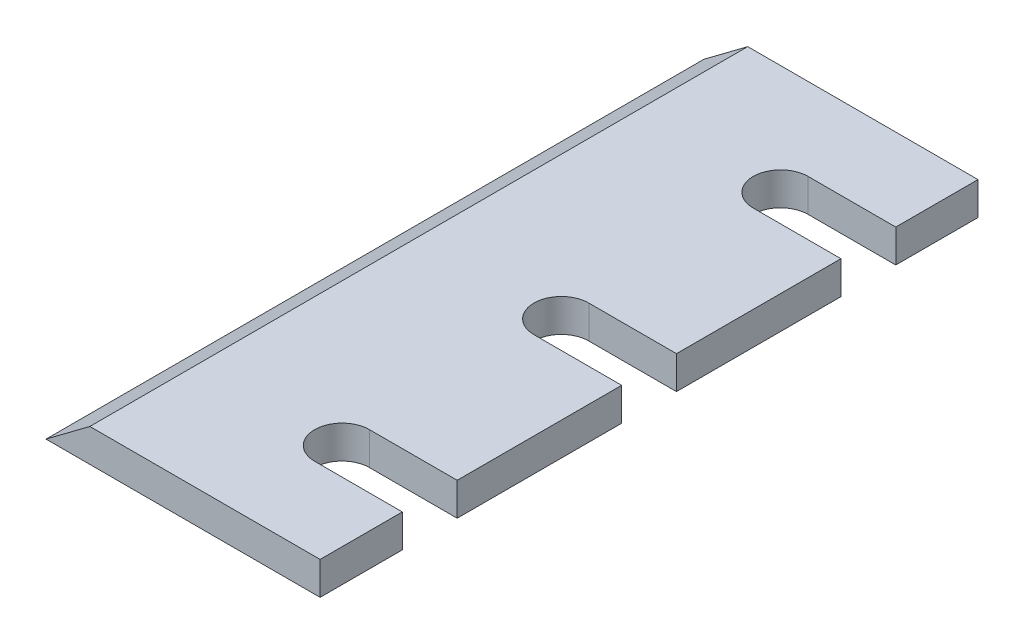
from build123d import *

# Parameters (mm, degrees)
AUFSATZ_LINEAR_AUSTRAGEN1_DEPTH = 60
SCHNITT_LINEAR_AUSTRAGEN1_DEPTH = 4


with BuildPart() as part:
    # Skizze1 → Aufsatz-Linear austragen1 (new body)
    with BuildSketch(Plane.XY):
        Polygon((0, 0), (25, 0), (25, 3), (4, 3), align=None)
    extrude(amount=AUFSATZ_LINEAR_AUSTRAGEN1_DEPTH)

    # Skizze2 → Schnitt-Linear austragen1 (cut, through all)
    with BuildSketch(Plane(origin=(0, 3, 0), x_dir=(1, 0, 0), z_dir=(0, 1, 0))):
        with BuildLine():
            Line((25, -52.5), (17, -52.5))
            ThreePointArc((17, -52.5), (14.5, -50), (17, -47.5))
            Line((17, -47.5), (25, -47.5))
            Line((25, -47.5), (25, -52.5))
        make_face()
        with BuildLine():
            Line((25, -32.5), (17, -32.5))
            ThreePointArc((17, -32.5), (14.5, -30), (17, -27.5))
            Line((17, -27.5), (25, -27.5))
            Line((25, -27.5), (25, -32.5))
        make_face()
        with BuildLine():
            Line((25, -12.5), (17, -12.5))
            ThreePointArc((17, -12.5), (14.5, -10), (17, -7.5))
            Line((17, -7.5), (25, -7.5))
            Line((25, -7.5), (25, -12.5))
        make_face()
    extrude(amount=-SCHNITT_LINEAR_AUSTRAGEN1_DEPTH, mode=Mode.SUBTRACT)


solid = part.part
